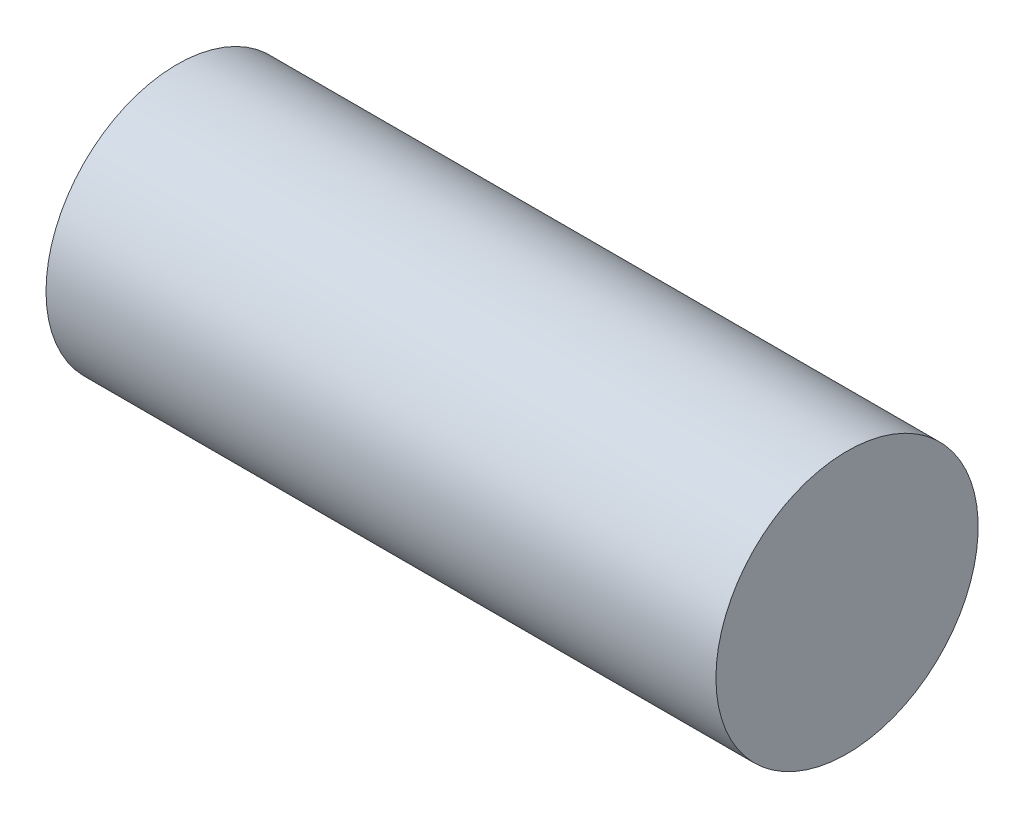
from build123d import *


with BuildPart() as part:
    # Sketch1 → Revolve1 (revolve)
    with BuildSketch(Plane.XY):
        Polygon((76.2, 0), (88.9, 0), (88.9, 17.399), (0, 17.399), (0, 9.525), (76.2, 9.525), align=None)
    revolve(axis=Axis((-44.071390532, 0, 0), (1, 0, 0)))


solid = part.part
